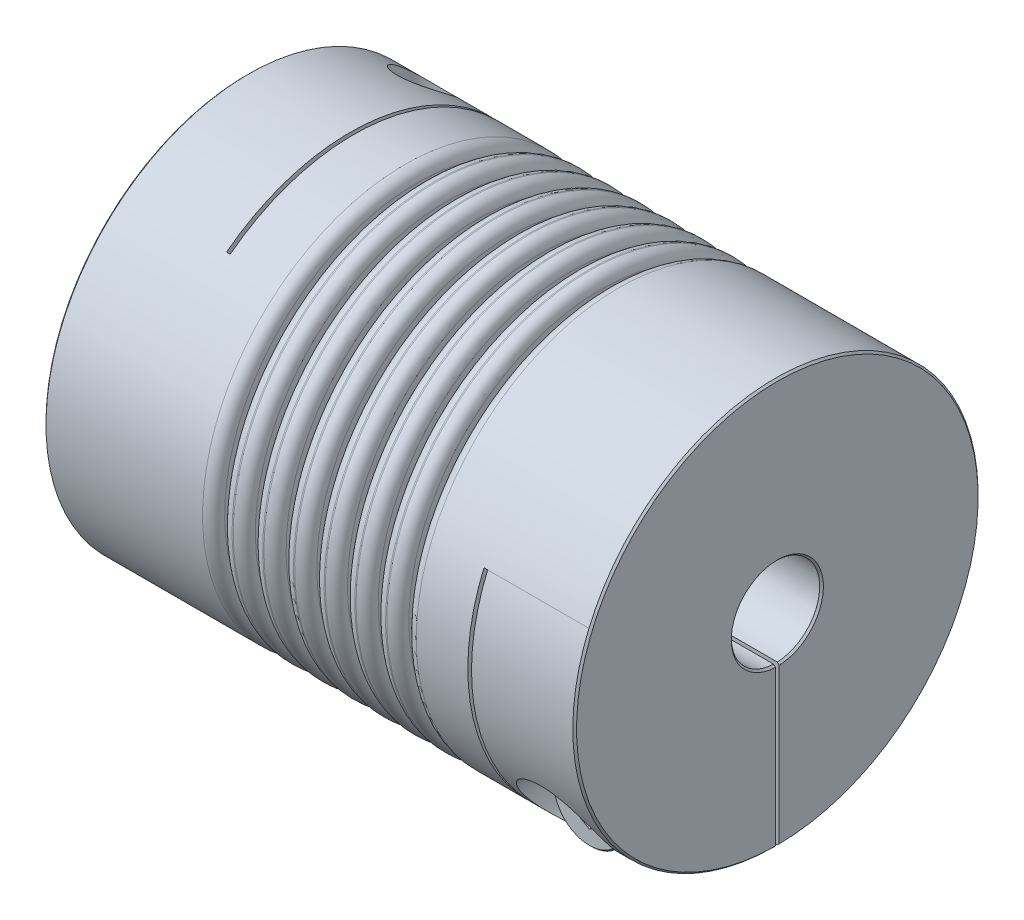
from build123d import *

# Parameters (mm, degrees)
SKETCH1_R                      = 27.5
BOSS_EXTRUDE1_DEPTH            = 36
SKETCH2_R                      = 6
CUT_EXTRUDE1_DEPTH             = 82.832145273
CHAMFER1_SIZE                  = 0.254
SKETCH4_W                      = 0.5
SKETCH4_H                      = 44.25
CUT_EXTRUDE2_DEPTH             = 72.254824398
SKETCH7_W                      = 0.5
SKETCH7_H                      = 38.25
CUT_EXTRUDE3_DEPTH             = 72.254824398
SKETCH8_W                      = 14
SKETCH8_H                      = 27.5
CUT_EXTRUDE5_DEPTH             = 0.25
SKETCH13_W                     = 14
SKETCH13_H                     = 27.5
CUT_EXTRUDE6_DEPTH             = 0.25
CBORE_FOR_M6_SHCS2_D           = 6.6
CBORE_FOR_M6_SHCS2_CBORE_D     = 11
CBORE_FOR_M6_SHCS2_CBORE_DEPTH = 15
CBORE_FOR_M6_SHCS1_D           = 6.6
CBORE_FOR_M6_SHCS1_CBORE_D     = 11
CBORE_FOR_M6_SHCS1_CBORE_DEPTH = 15
SKETCH16_R                     = 5
BOSS_EXTRUDE2_DEPTH            = 6
SKETCH17_R                     = 1.25
BOSS_EXTRUDE3_DEPTH            = 8
CHAMFER2_SIZE                  = 0.2
CUT_EXTRUDE7_DEPTH             = 1.5
CIRPATTERN1_COUNT              = 2
CIRPATTERN1_ANGLE              = 90
SKETCH19_W                     = 1
SKETCH19_H                     = 7.5
FILLET1_R                      = 1.5
FILLET2_R                      = 0.1


with BuildPart() as part:
    # Sketch1 → Boss-Extrude1 (new, symmetric)
    with BuildSketch(Plane(origin=(0, 0, 0), x_dir=(0, 0, -1), z_dir=(1, 0, 0))):
        Circle(SKETCH1_R)
    extrude(amount=BOSS_EXTRUDE1_DEPTH, both=True)

    # Sketch2 → Cut-Extrude1 (cut, through all)
    with BuildSketch(Plane(origin=(36, 0, 0), x_dir=(0, 0, -1), z_dir=(1, 0, 0))):
        Circle(SKETCH2_R)
    extrude(amount=-CUT_EXTRUDE1_DEPTH, mode=Mode.SUBTRACT)

    # Chamfer1
    chamfer1_edges = [part.edges().sort_by_distance(p)[0] for p in [
        (-36, 0, 27.5),
        (36, 0, 27.5),
        (-36, 0, 6),
        (36, 0, 6),
    ]]
    chamfer(chamfer1_edges, length=CHAMFER1_SIZE)

    # Sketch4 → Cut-Extrude2 (cut, through all)
    with BuildSketch(Plane.XZ.offset(27.5)):
        with Locations((-21.75, -5.375)):
            Rectangle(SKETCH4_W, SKETCH4_H)
    extrude(amount=-CUT_EXTRUDE2_DEPTH, mode=Mode.SUBTRACT)

    # Sketch7 → Cut-Extrude3 (cut, through all)
    with BuildSketch(Plane(origin=(0, 0, -27.5), x_dir=(-1, 0, 0), z_dir=(0, 0, -1))):
        with Locations((-21.75, -8.375)):
            Rectangle(SKETCH7_W, SKETCH7_H)
    extrude(amount=-CUT_EXTRUDE3_DEPTH, mode=Mode.SUBTRACT)

    # Sketch8 → Cut-Extrude5 (cut, symmetric)
    with BuildSketch(Plane(origin=(0, 0, 0), x_dir=(1, 0, 0), z_dir=(0, 1, 0))):
        with Locations((-29, 13.75)):
            Rectangle(SKETCH8_W, SKETCH8_H)
    extrude(amount=CUT_EXTRUDE5_DEPTH, both=True, mode=Mode.SUBTRACT)

    # Sketch13 → Cut-Extrude6 (cut, symmetric)
    with BuildSketch(Plane.XY):
        with Locations((29, -13.75)):
            Rectangle(SKETCH13_W, SKETCH13_H)
    extrude(amount=CUT_EXTRUDE6_DEPTH, both=True, mode=Mode.SUBTRACT)

    # CBORE for M6 SHCS2 (through all)
    with Locations(Plane.XZ.offset(27.5)):
        with Locations((-29, -16.746826509)):
            CounterBoreHole(CBORE_FOR_M6_SHCS2_D / 2, CBORE_FOR_M6_SHCS2_CBORE_D / 2, CBORE_FOR_M6_SHCS2_CBORE_DEPTH)

    # CBORE for M6 SHCS1 (through all)
    with Locations(Plane.XY.offset(27.5)):
        with Locations((29, -16.746826509)):
            CounterBoreHole(CBORE_FOR_M6_SHCS1_D / 2, CBORE_FOR_M6_SHCS1_CBORE_D / 2, CBORE_FOR_M6_SHCS1_CBORE_DEPTH)

    # Sketch19 → Cut-Revolve1 (revolve, cut)
    with BuildSketch(Plane.XY):
        with Locations((0, 23.75)):
            Rectangle(SKETCH19_W, SKETCH19_H)
        with Locations((4.166666667, 23.75)):
            Rectangle(SKETCH19_W, SKETCH19_H)
        with Locations((8.333333333, 23.75)):
            Rectangle(SKETCH19_W, SKETCH19_H)
        with Locations((12.5, 23.75)):
            Rectangle(SKETCH19_W, SKETCH19_H)
        with Locations((-12.5, 23.75)):
            Rectangle(SKETCH19_W, SKETCH19_H)
        with Locations((-8.333333333, 23.75)):
            Rectangle(SKETCH19_W, SKETCH19_H)
        with Locations((-4.166666667, 23.75)):
            Rectangle(SKETCH19_W, SKETCH19_H)
    revolve(axis=Axis((0, 0, 0), (-1, 0, 0)), mode=Mode.SUBTRACT)

    # Fillet1
    fillet1_edges = [part.edges().sort_by_distance(p)[0] for p in [
        (0.5, 0, 27.5),
        (-0.5, 0, 27.5),
        (-13, 0, 27.5),
        (-12, 0, 27.5),
        (4.666666667, 0, 27.5),
        (3.666666667, 0, 27.5),
        (8.833333333, 0, 27.5),
        (7.833333333, 0, 27.5),
        (13, 0, 27.5),
        (12, 0, 27.5),
        (-8.833333333, 0, 27.5),
        (-7.833333333, 0, 27.5),
        (-4.666666667, 0, 27.5),
        (-3.666666667, 0, 27.5),
    ]]
    fillet(fillet1_edges, radius=FILLET1_R)

    # Fillet2
    fillet2_edges = [part.edges().sort_by_distance(p)[0] for p in [
        (-0.5, -20, 0),
        (0.5, -20, 0),
        (-13, -20, 0),
        (-12, -20, 0),
        (3.666666667, -20, 0),
        (4.666666667, -20, 0),
        (7.833333333, -20, 0),
        (8.833333333, -20, 0),
        (12, -20, 0),
        (13, -20, 0),
        (-8.833333333, -20, 0),
        (-7.833333333, -20, 0),
        (-4.666666667, -20, 0),
        (-3.666666667, -20, 0),
    ]]
    fillet(fillet2_edges, radius=FILLET2_R)


with BuildPart() as body_2:
    # Sketch16 → Boss-Extrude2 (new body)
    with BuildSketch(Plane.XY.offset(12.5)):
        with Locations((29, -16.746826509)):
            Circle(SKETCH16_R)
    extrude(amount=BOSS_EXTRUDE2_DEPTH)

    # Sketch17 → Boss-Extrude3 (add)
    with BuildSketch(Plane(origin=(0, 0, 12.5), x_dir=(-1, 0, 0), z_dir=(0, 0, -1))):
        with Locations(Location((-29, -16.746826509, 0), (0, 0, 180))):
            Circle(SKETCH17_R)
    extrude(amount=BOSS_EXTRUDE3_DEPTH)

    # Chamfer2
    chamfer2_edges = [body_2.edges().sort_by_distance(p)[0] for p in [
        (24, -16.746826509, 12.5),
        (24, -16.746826509, 18.5),
        (27.75, -16.746826509, 4.5),
    ]]
    chamfer(chamfer2_edges, length=CHAMFER2_SIZE)

    # Sketch18 → Cut-Extrude7 (cut)
    with BuildSketch(Plane.XY.offset(18.5)):
        Polygon((29, -19.633577854), (31.5, -18.190202181), (31.5, -15.303450836), (29, -13.860075163), (26.5, -15.303450836), (26.5, -18.190202181), align=None)
    extrude(amount=-CUT_EXTRUDE7_DEPTH, mode=Mode.SUBTRACT)


with BuildPart() as body_3:
    # Mirror1: mirrored copy
    add(body_2.part.mirror(Plane(origin=(0, 0, 0), x_dir=(0, 0, 1), z_dir=(1, 0, 0))))


with BuildPart() as cirpattern1_1:
    # CirPattern1: pattern copy
    add(body_3.part.rotate(Axis((0, 0, 0), (1, 0, 0)), 1 * CIRPATTERN1_ANGLE / (CIRPATTERN1_COUNT - 1)))


solid = Compound([part.part, body_2.part, cirpattern1_1.part])
